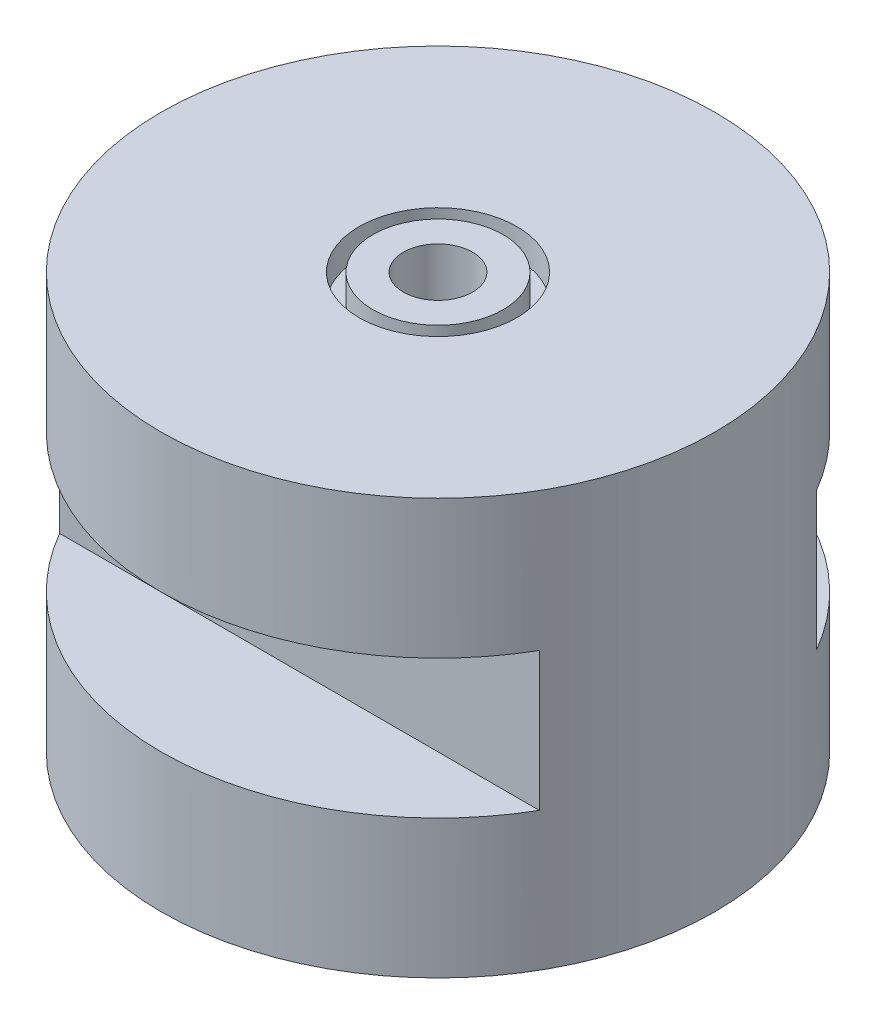
from build123d import *

# Parameters (mm, degrees)
ESQUISSE1_R                  = 10
BOSS_EXTRU_1_DEPTH           = 15
ESQUISSE2_R                  = 2.85
ESQUISSE2_R_2                = 2.35
ENL_V_MAT_EXTRU_1_DEPTH      = 1
ESQUISSE3_R                  = 1.25
ENL_V_MAT_EXTRU_2_DEPTH      = 16
ESQUISSE4_W                  = 5
ESQUISSE4_H                  = 5
ENL_V_MAT_EXTRU_3_DEPTH      = 11
ENL_V_MAT_EXTRU_3_DEPTH_BACK = 11


with BuildPart() as part:
    # Esquisse1 → Boss.-Extru.1 (new body)
    with BuildSketch(Plane(origin=(0, 0, 0), x_dir=(1, 0, 0), z_dir=(0, 1, 0))):
        Circle(ESQUISSE1_R)
    extrude(amount=BOSS_EXTRU_1_DEPTH)

    # Esquisse2 → Enlèv. mat.-Extru.1 (cut)
    with BuildSketch(Plane(origin=(0, 15, 0), x_dir=(1, 0, 0), z_dir=(0, 1, 0))):
        Circle(ESQUISSE2_R)
        Circle(ESQUISSE2_R_2, mode=Mode.SUBTRACT)
    extrude(amount=-ENL_V_MAT_EXTRU_1_DEPTH, mode=Mode.SUBTRACT)

    # Esquisse3 → Enlèv. mat.-Extru.2 (cut, through all)
    with BuildSketch(Plane(origin=(0, 15, 0), x_dir=(1, 0, 0), z_dir=(0, 1, 0))):
        Circle(ESQUISSE3_R)
    extrude(amount=-ENL_V_MAT_EXTRU_2_DEPTH, mode=Mode.SUBTRACT)

    # Esquisse4 → Enlèv. mat.-Extru.3 (cut, two sides)
    with BuildSketch(Plane(origin=(0, 0, 0), x_dir=(0, 0, -1), z_dir=(1, 0, 0))) as enl_v_mat_extru_3_sk:
        with Locations((-7.5, 7.5)):
            Rectangle(ESQUISSE4_W, ESQUISSE4_H)
        with Locations((7.5, 7.5)):
            Rectangle(ESQUISSE4_W, ESQUISSE4_H)
    extrude(amount=ENL_V_MAT_EXTRU_3_DEPTH, mode=Mode.SUBTRACT)
    extrude(enl_v_mat_extru_3_sk.sketch, amount=-ENL_V_MAT_EXTRU_3_DEPTH_BACK, mode=Mode.SUBTRACT)


solid = part.part
